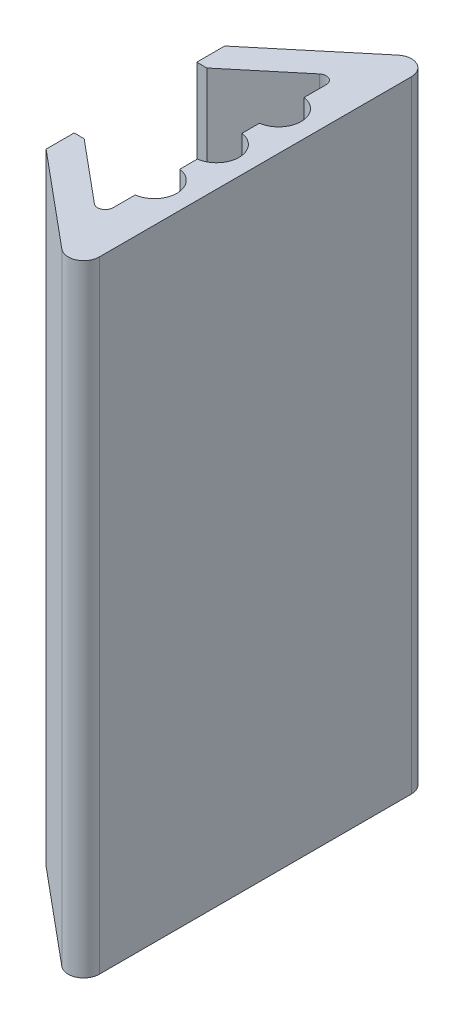
from build123d import *

# Parameters (mm, degrees)
BOSS_EXTRUDE1_DEPTH = 80


with BuildPart() as part:
    # Sketch1 → Boss-Extrude1 (new body)
    with BuildSketch(Plane(origin=(0, 0, 0), x_dir=(1, 0, 0), z_dir=(0, 1, 0))):
        with BuildLine():
            Line((18.551800259, 11.5), (18.551800259, 7.9))
            Line((18.551800259, 7.9), (19.855180026, 7.9))
            Line((19.855180026, 7.9), (27.7598156, 14.487196312))
            ThreePointArc((27.7598156, 14.487196312), (28.824155396, 14.624564454), (29.4, 13.718975032))
            Line((29.4, 13.718975032), (29.4, 10.872281323))
            ThreePointArc((29.4, 10.872281323), (31.9, 8), (29.4, 5.127718677))
            Line((29.4, 5.127718677), (29.4, 2.872281323))
            ThreePointArc((29.4, 2.872281323), (31.9, 0), (29.4, -2.872281323))
            Line((29.4, -2.872281323), (29.4, -5.127718677))
            ThreePointArc((29.4, -5.127718677), (31.9, -8), (29.4, -10.872281323))
            Line((29.4, -10.872281323), (29.4, -13.718975032))
            ThreePointArc((29.4, -13.718975032), (28.824155396, -14.624564454), (27.7598156, -14.487196312))
            Line((27.7598156, -14.487196312), (19.845818206, -7.892198484))
            Line((19.845818206, -7.892198484), (18.551800259, -7.892198484))
            Line((18.551800259, -7.892198484), (18.551800259, -11.5))
            Line((18.551800259, -11.5), (30.719631201, -21.639859118))
            ThreePointArc((30.719631201, -21.639859118), (32.848310792, -21.914595401), (34, -20.103416559))
            Line((34, -20.103416559), (34, 20.103416559))
            ThreePointArc((34, 20.103416559), (32.848310792, 21.914595401), (30.719631201, 21.639859118))
            Line((30.719631201, 21.639859118), (18.551800259, 11.5))
        make_face()
    extrude(amount=BOSS_EXTRUDE1_DEPTH)


solid = part.part
